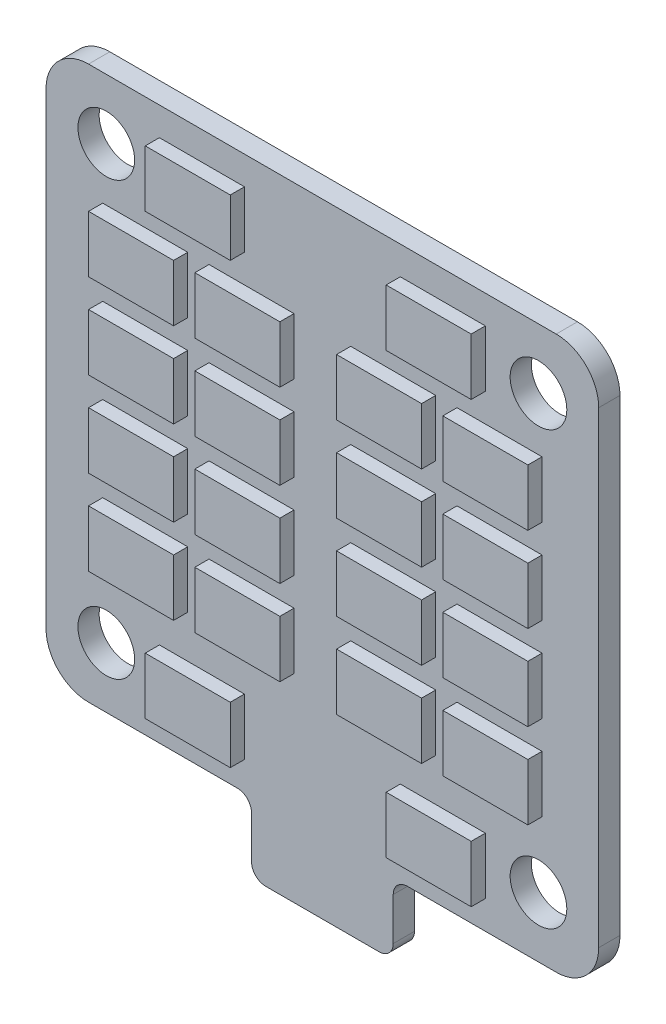
from build123d import *

# Parameters (mm, degrees)
SKETCH2_R           = 2
BOSS_EXTRUDE1_DEPTH = 1.5
SKETCH3_W           = 6
SKETCH3_H           = 4
BOSS_EXTRUDE2_DEPTH = 1


with BuildPart() as part:
    # Sketch2 → Boss-Extrude1 (new body)
    with BuildSketch(Plane.XY):
        with BuildLine():
            Line((-16.5, -19.5), (-6, -19.5))
            ThreePointArc((-6, -19.5), (-5.292893219, -19.792893219), (-5, -20.5))
            Line((-5, -20.5), (-5, -23.5))
            ThreePointArc((-5, -23.5), (-4.707106781, -24.207106781), (-4, -24.5))
            Line((-4, -24.5), (4, -24.5))
            ThreePointArc((4, -24.5), (4.707106781, -24.207106781), (5, -23.5))
            Line((5, -23.5), (5, -20.5))
            ThreePointArc((5, -20.5), (5.292893219, -19.792893219), (6, -19.5))
            Line((6, -19.5), (16.5, -19.5))
            ThreePointArc((16.5, -19.5), (18.621320344, -18.621320344), (19.5, -16.5))
            Line((19.5, -16.5), (19.5, 16.5))
            ThreePointArc((19.5, 16.5), (18.621320344, 18.621320344), (16.5, 19.5))
            Line((16.5, 19.5), (-16.5, 19.5))
            ThreePointArc((-16.5, 19.5), (-18.621320344, 18.621320344), (-19.5, 16.5))
            Line((-19.5, 16.5), (-19.5, -16.5))
            ThreePointArc((-19.5, -16.5), (-18.621320344, -18.621320344), (-16.5, -19.5))
        make_face()
        with Locations((15.25, 15.25)):
            Circle(SKETCH2_R, mode=Mode.SUBTRACT)
        with Locations((15.25, -15.25)):
            Circle(SKETCH2_R, mode=Mode.SUBTRACT)
        with Locations((-15.25, -15.25)):
            Circle(SKETCH2_R, mode=Mode.SUBTRACT)
        with Locations((-15.25, 15.25)):
            Circle(SKETCH2_R, mode=Mode.SUBTRACT)
    extrude(amount=BOSS_EXTRUDE1_DEPTH)

    # Sketch3 → Boss-Extrude2 (add)
    with BuildSketch(Plane.XY.offset(1.5)):
        with Locations((-5, 3.5)):
            Rectangle(SKETCH3_W, SKETCH3_H)
        with Locations((-5, 9.5)):
            Rectangle(SKETCH3_W, SKETCH3_H)
        with Locations((-5, -2.5)):
            Rectangle(SKETCH3_W, SKETCH3_H)
        with Locations((-5, -8.5)):
            Rectangle(SKETCH3_W, SKETCH3_H)
        with Locations((-12.5, 9.5)):
            Rectangle(SKETCH3_W, SKETCH3_H)
        with Locations((-12.5, 3.5)):
            Rectangle(SKETCH3_W, SKETCH3_H)
        with Locations((-12.5, -2.5)):
            Rectangle(SKETCH3_W, SKETCH3_H)
        with Locations((-12.5, -8.5)):
            Rectangle(SKETCH3_W, SKETCH3_H)
        with Locations((12.5, -8.5)):
            Rectangle(SKETCH3_W, SKETCH3_H)
        with Locations((12.5, -2.5)):
            Rectangle(SKETCH3_W, SKETCH3_H)
        with Locations((12.5, 3.5)):
            Rectangle(SKETCH3_W, SKETCH3_H)
        with Locations((12.5, 9.5)):
            Rectangle(SKETCH3_W, SKETCH3_H)
        with Locations((5, -8.5)):
            Rectangle(SKETCH3_W, SKETCH3_H)
        with Locations((5, -2.5)):
            Rectangle(SKETCH3_W, SKETCH3_H)
        with Locations((5, 3.5)):
            Rectangle(SKETCH3_W, SKETCH3_H)
        with Locations((5, 9.5)):
            Rectangle(SKETCH3_W, SKETCH3_H)
        with Locations((8.5, 15.5)):
            Rectangle(SKETCH3_W, SKETCH3_H)
        with Locations((-8.5, 15.5)):
            Rectangle(SKETCH3_W, SKETCH3_H)
        with Locations((8.5, -15.5)):
            Rectangle(SKETCH3_W, SKETCH3_H)
        with Locations((-8.5, -15.5)):
            Rectangle(SKETCH3_W, SKETCH3_H)
    extrude(amount=BOSS_EXTRUDE2_DEPTH)


solid = part.part
